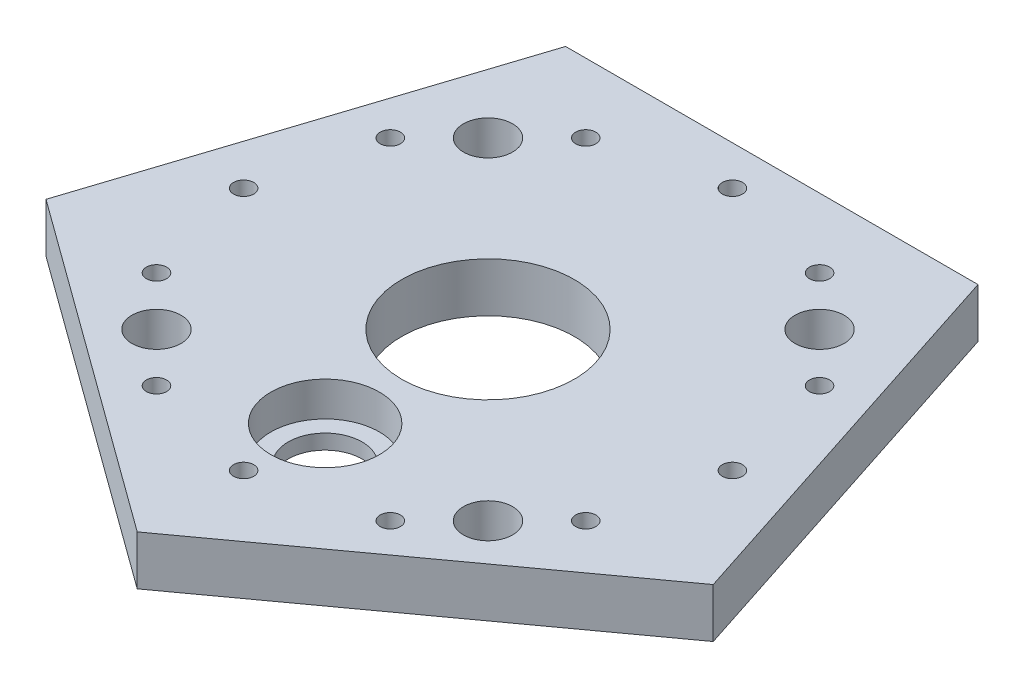
from build123d import *

# Parameters (mm, degrees)
BOSS_EXTRUDE1_DEPTH = 10
SKETCH2_R           = 11
CUT_EXTRUDE1_DEPTH  = 7
SKETCH3_R           = 7.5
CUT_EXTRUDE2_DEPTH  = 4
SKETCH5_R           = 4.975
SKETCH5_R_2         = 2.05
CUT_EXTRUDE4_DEPTH  = 11
SKETCH6_R           = 2.05
CUT_EXTRUDE5_DEPTH  = 11
CIRPATTERN1_COUNT   = 4
SKETCH7_R           = 17.5
CUT_EXTRUDE6_DEPTH  = 11


with BuildPart() as part:
    # Sketch1 → Boss-Extrude1 (new body)
    with BuildSketch(Plane(origin=(0, 0, 0), x_dir=(1, 0, 0), z_dir=(0, 1, 0))):
        Polygon((0, -71.073908706), (67.595304014, -21.963045647), (41.77619536, 57.5), (-41.77619536, 57.5), (-67.595304014, -21.963045647), align=None)
    extrude(amount=BOSS_EXTRUDE1_DEPTH)

    # Sketch2 → Cut-Extrude1 (cut)
    with BuildSketch(Plane(origin=(0, 10, 0), x_dir=(1, 0, 0), z_dir=(0, 1, 0))):
        with Locations((0, -33)):
            Circle(SKETCH2_R)
    extrude(amount=-CUT_EXTRUDE1_DEPTH, mode=Mode.SUBTRACT)

    # Sketch3 → Cut-Extrude2 (cut, through all)
    with BuildSketch(Plane(origin=(0, 3, 0), x_dir=(1, 0, 0), z_dir=(0, 1, 0))):
        with Locations((0, -33)):
            Circle(SKETCH3_R)
    extrude(amount=-CUT_EXTRUDE2_DEPTH, mode=Mode.SUBTRACT)

    # Sketch5 → Cut-Extrude4 (cut, through all)
    with BuildSketch(Plane(origin=(0, 10, 0), x_dir=(1, 0, 0), z_dir=(0, 1, 0))):
        with Locations((-33.587572106, -33.587572106)):
            Circle(SKETCH5_R)
        with Locations((-43.487067043, -23.68807717)):
            Circle(SKETCH5_R_2)
        with Locations((-23.68807717, -43.487067043)):
            Circle(SKETCH5_R_2)
    cut_extrude4 = extrude(amount=-CUT_EXTRUDE4_DEPTH, mode=Mode.SUBTRACT)

    # Sketch6 → Cut-Extrude5 (cut, through all)
    with BuildSketch(Plane(origin=(0, 10, 0), x_dir=(1, 0, 0), z_dir=(0, 1, 0))):
        with Locations((0, -49.52)):
            Circle(SKETCH6_R)
    cut_extrude5 = extrude(amount=-CUT_EXTRUDE5_DEPTH, mode=Mode.SUBTRACT)

    # CirPattern1: Cut-Extrude4, Cut-Extrude5 ×4 about axis
    cirpattern1_axis = Axis((0, 0, 0), (0, 1, 0))
    for i in range(1, CIRPATTERN1_COUNT):
        add(cut_extrude4.rotate(cirpattern1_axis, i * 360 / CIRPATTERN1_COUNT), mode=Mode.SUBTRACT)
        add(cut_extrude5.rotate(cirpattern1_axis, i * 360 / CIRPATTERN1_COUNT), mode=Mode.SUBTRACT)

    # Sketch7 → Cut-Extrude6 (cut, through all)
    with BuildSketch(Plane(origin=(0, 10, 0), x_dir=(1, 0, 0), z_dir=(0, 1, 0))):
        Circle(SKETCH7_R)
    extrude(amount=-CUT_EXTRUDE6_DEPTH, mode=Mode.SUBTRACT)


solid = part.part
